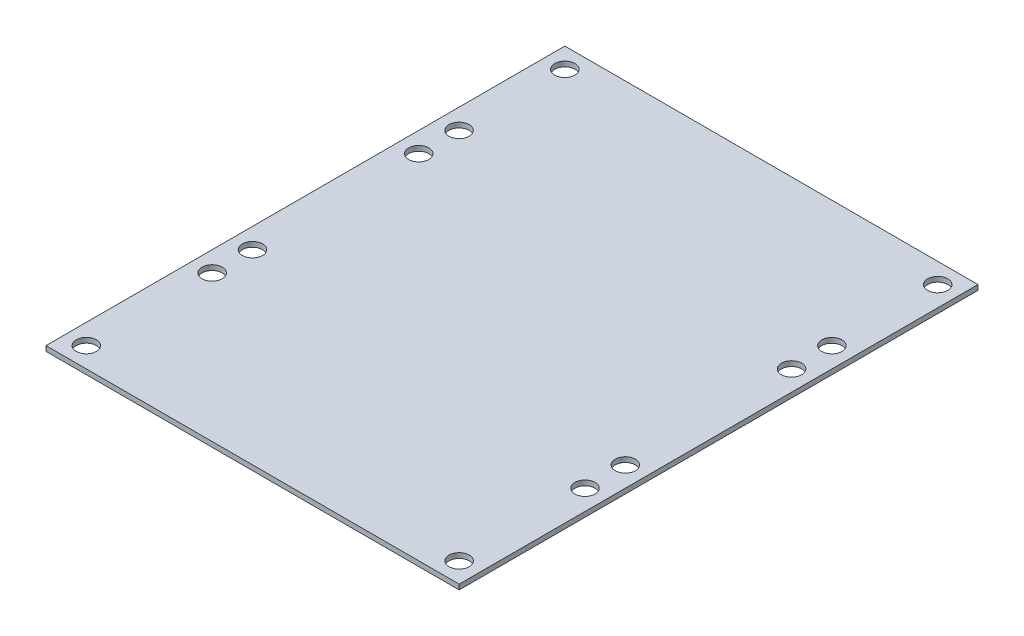
from build123d import *

# Parameters (mm, degrees)
SKETCH1_W           = 130.175
SKETCH1_H           = 163.4744
SKETCH1_R           = 3.175
BOSS_EXTRUDE1_DEPTH = 1.5875


with BuildPart() as part:
    # Sketch1 → Boss-Extrude1 (new body)
    with BuildSketch(Plane(origin=(0, 0, 0), x_dir=(1, 0, 0), z_dir=(0, 1, 0))):
        with Locations((65.0875, 81.7372)):
            Rectangle(SKETCH1_W, SKETCH1_H)
        with Locations((6.35, 6.35)):
            Circle(SKETCH1_R, mode=Mode.SUBTRACT)
        with Locations((6.35, 157.1244)):
            Circle(SKETCH1_R, mode=Mode.SUBTRACT)
        with Locations((123.825, 6.35)):
            Circle(SKETCH1_R, mode=Mode.SUBTRACT)
        with Locations((123.825, 157.1244)):
            Circle(SKETCH1_R, mode=Mode.SUBTRACT)
        with Locations((6.35, 123.7869)):
            Circle(SKETCH1_R, mode=Mode.SUBTRACT)
        with Locations((6.35, 111.0869)):
            Circle(SKETCH1_R, mode=Mode.SUBTRACT)
        with Locations((6.35, 58.6994)):
            Circle(SKETCH1_R, mode=Mode.SUBTRACT)
        with Locations((6.35, 45.9994)):
            Circle(SKETCH1_R, mode=Mode.SUBTRACT)
        with Locations((123.825, 123.7869)):
            Circle(SKETCH1_R, mode=Mode.SUBTRACT)
        with Locations((123.825, 111.0869)):
            Circle(SKETCH1_R, mode=Mode.SUBTRACT)
        with Locations((123.825, 58.6994)):
            Circle(SKETCH1_R, mode=Mode.SUBTRACT)
        with Locations((123.825, 45.9994)):
            Circle(SKETCH1_R, mode=Mode.SUBTRACT)
    extrude(amount=BOSS_EXTRUDE1_DEPTH)


solid = part.part
